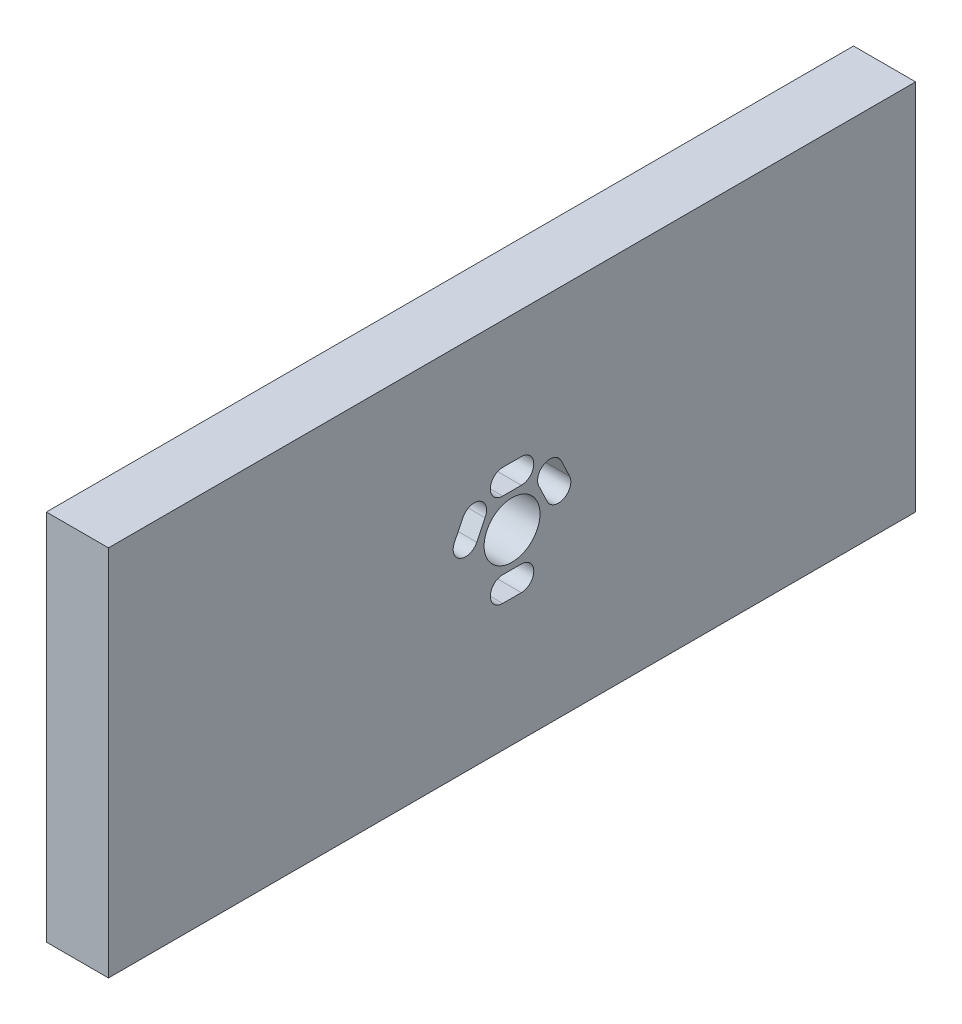
from build123d import *

# Parameters (mm, degrees)
SKETCH1_W           = 130
SKETCH1_H           = 60
SKETCH1_R           = 4.499999999
BOSS_EXTRUDE1_DEPTH = 10


with BuildPart() as part:
    # Sketch1 → Boss-Extrude1 (new body)
    with BuildSketch(Plane(origin=(0, 0, 0), x_dir=(0, 0, -1), z_dir=(1, 0, 0))):
        with Locations((3.813160791, 27.897530874)):
            Rectangle(SKETCH1_W, SKETCH1_H)
        with Locations((3.813160791, 27.897530874)):
            Circle(SKETCH1_R, mode=Mode.SUBTRACT)
        with BuildLine():
            Line((-5.464379102, 30.775341326), (-4.081605515, 33.606305024))
            ThreePointArc((-4.081605515, 33.606305024), (-1.369183898, 34.499769949), (-0.528409533, 31.770555947))
            Line((-0.528409533, 31.770555947), (-1.869576404, 29.020756356))
            ThreePointArc((-1.869576404, 29.020756356), (-4.544523089, 28.10012945), (-5.464379102, 30.775341326))
        make_face(mode=Mode.SUBTRACT)
        with BuildLine():
            Line((5.31316079, 18.397530874), (2.313160791, 18.397530874))
            ThreePointArc((2.313160791, 18.397530874), (0.313160792, 20.397530874), (2.313160791, 22.397530873))
            Line((2.313160791, 22.397530873), (5.31316079, 22.397530873))
            ThreePointArc((5.31316079, 22.397530873), (7.313160789, 20.397530874), (5.31316079, 18.397530874))
        make_face(mode=Mode.SUBTRACT)
        with BuildLine():
            Line((5.31316079, 33.374248764), (2.313160791, 33.374248764))
            ThreePointArc((2.313160791, 33.374248764), (0.31316079, 35.374248765), (2.313160791, 37.374248765))
            Line((2.313160791, 37.374248765), (5.31316079, 37.374248765))
            ThreePointArc((5.31316079, 37.374248765), (7.313160791, 35.374248765), (5.31316079, 33.374248764))
        make_face(mode=Mode.SUBTRACT)
        with BuildLine():
            Line((9.471997672, 29.038205562), (8.081045524, 31.961596177))
            ThreePointArc((8.081045524, 31.961596177), (9.113942414, 34.555839775), (11.733632625, 33.589300054))
            Line((11.733632625, 33.589300054), (13.083423708, 30.758314735))
            ThreePointArc((13.083423708, 30.758314735), (12.137765277, 28.092547131), (9.471997672, 29.038205562))
        make_face(mode=Mode.SUBTRACT)
    extrude(amount=BOSS_EXTRUDE1_DEPTH)


solid = part.part
